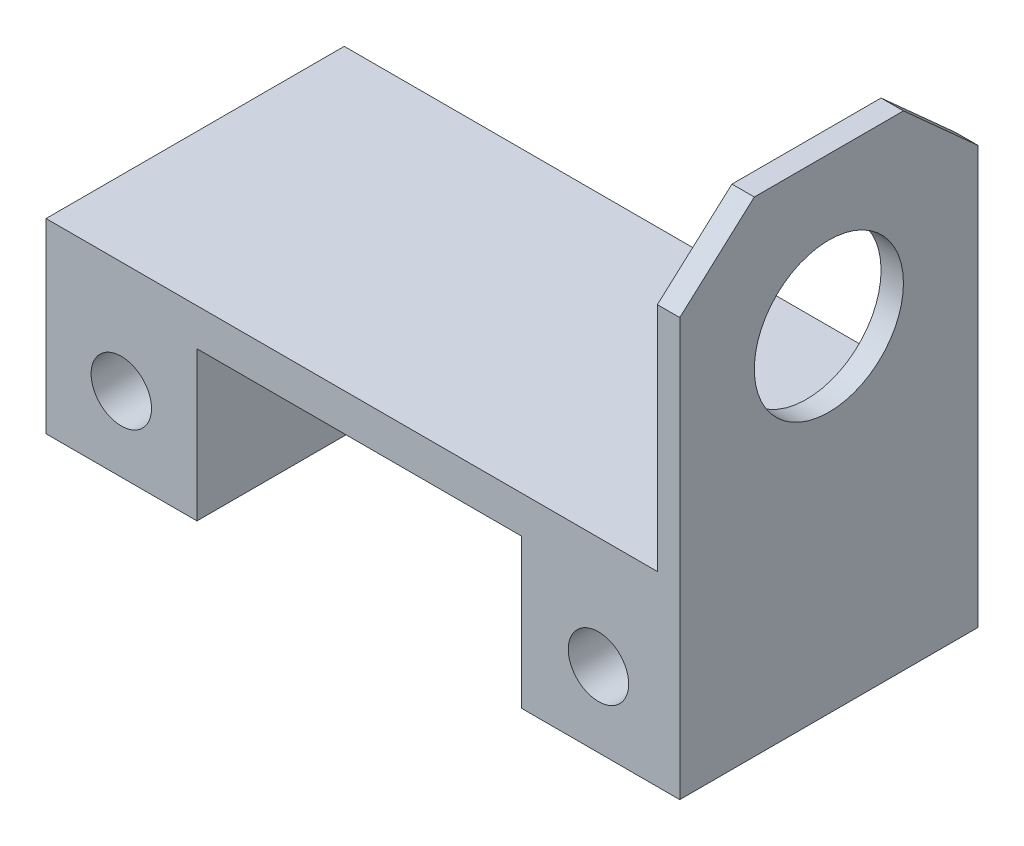
from build123d import *

# Parameters (mm, degrees)
CROQUIS1_R              = 4.05
SALIENTE_EXTRUIR2_DEPTH = 40
SALIENTE_EXTRUIR3_DEPTH = 3
CROQUIS4_R              = 10
CORTAR_EXTRUIR2_DEPTH   = 86


with BuildPart() as part:
    # Croquis1 → Saliente-Extruir2 (new body)
    with BuildSketch(Plane.XY):
        Polygon((42, 12.5), (-42, 12.5), (-42, -12.5), (-21.75, -12.5), (-21.75, 7.5), (21.75, 7.5), (21.75, -12.5), (42, -12.5), align=None)
        with Locations((-31.902194282, -2.5)):
            Circle(CROQUIS1_R, mode=Mode.SUBTRACT)
        with Locations((32.097805718, -2.5)):
            Circle(CROQUIS1_R, mode=Mode.SUBTRACT)
    extrude(amount=-SALIENTE_EXTRUIR2_DEPTH)

    # Croquis3 → Saliente-Extruir3 (add)
    with BuildSketch(Plane(origin=(40, 0, 0), x_dir=(0, 0, -1), z_dir=(1, 0, 0))):
        Polygon((30, 52.5), (40, 43.5), (40, -12.5), (0, -12.5), (0, 43.5), (10, 52.5), align=None)
    extrude(amount=SALIENTE_EXTRUIR3_DEPTH)

    # Croquis4 → Cortar-Extruir2 (cut, through all)
    with BuildSketch(Plane(origin=(43, 0, 0), x_dir=(0, 0, -1), z_dir=(1, 0, 0))):
        with Locations((20, 32.5)):
            Circle(CROQUIS4_R)
    extrude(amount=-CORTAR_EXTRUIR2_DEPTH, mode=Mode.SUBTRACT)


solid = part.part
